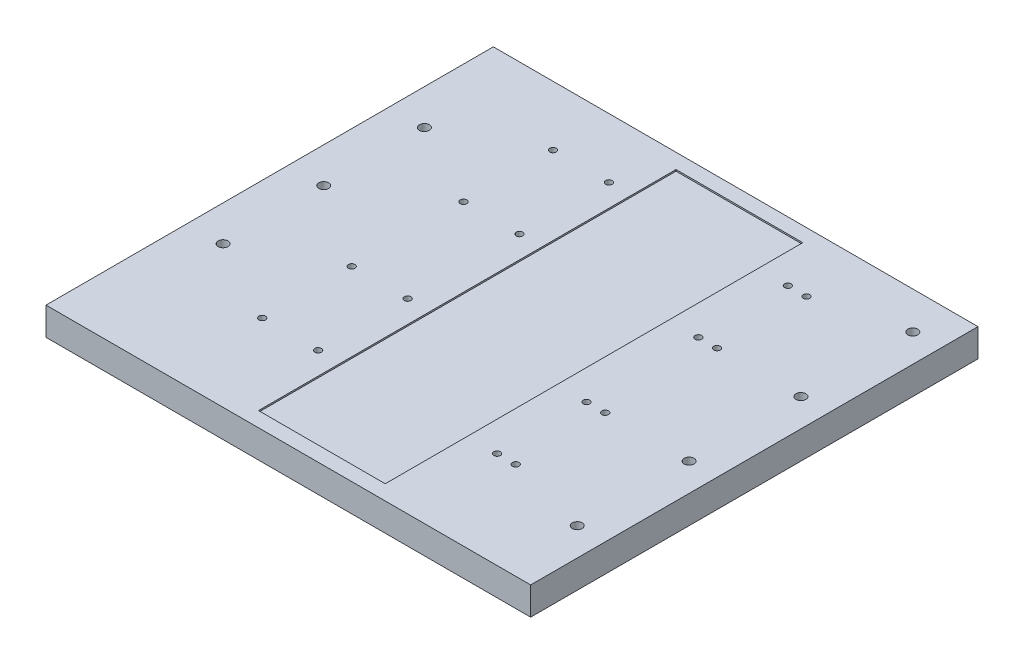
from build123d import *

# Parameters (mm, degrees)
SKETCH1_W                                            = 330.2
SKETCH1_H                                            = 304.8
BOSS_EXTRUDE1_DEPTH                                  = 19.05
SKETCH2_W                                            = 86.36
SKETCH2_H                                            = 284.48
CUT_EXTRUDE1_DEPTH                                   = 1.016
CBORE_FOR_8_SOCKET_HEAD_CAP_SCREW1_D                 = 4.4958
CBORE_FOR_8_SOCKET_HEAD_CAP_SCREW1_CBORE_D           = 7.9375
CBORE_FOR_8_SOCKET_HEAD_CAP_SCREW1_CBORE_DEPTH       = 4.1656
CBORE_FOR_1_4_BINDING_HEAD_MACHINE_SCREW_D           = 6.7564
CBORE_FOR_1_4_BINDING_HEAD_MACHINE_SCREW_CBORE_D     = 14.2875
CBORE_FOR_1_4_BINDING_HEAD_MACHINE_SCREW_CBORE_DEPTH = 4.191


with BuildPart() as part:
    # Sketch1 → Boss-Extrude1 (new body)
    with BuildSketch(Plane(origin=(0, 0, 0), x_dir=(1, 0, 0), z_dir=(0, 1, 0))):
        with Locations((165.1, -152.4)):
            Rectangle(SKETCH1_W, SKETCH1_H)
    extrude(amount=BOSS_EXTRUDE1_DEPTH)

    # Sketch2 → Cut-Extrude1 (cut)
    with BuildSketch(Plane(origin=(0, 19.05, 0), x_dir=(1, 0, 0), z_dir=(0, 1, 0))):
        with Locations((177.8, -152.4)):
            Rectangle(SKETCH2_W, SKETCH2_H)
    extrude(amount=-CUT_EXTRUDE1_DEPTH, mode=Mode.SUBTRACT)

    # CBORE for #8 Socket Head Cap Screw1 (through all)
    with Locations(Plane(origin=(0, 0, 0), x_dir=(-1, 0, 0), z_dir=(0, -1, 0))):
        with Locations((-241.3, -40.64), (-254, -40.64), (-254, -101.6), (-241.3, -101.6), (-241.3, -177.8), (-254, -177.8), (-254, -238.76), (-241.3, -238.76), (-119.38, -40.64), (-81.28, -40.64), (-81.28, -101.6), (-119.38, -101.6), (-119.38, -177.8), (-81.28, -177.8), (-81.28, -238.76), (-119.38, -238.76)):
            CounterBoreHole(CBORE_FOR_8_SOCKET_HEAD_CAP_SCREW1_D / 2, CBORE_FOR_8_SOCKET_HEAD_CAP_SCREW1_CBORE_D / 2, CBORE_FOR_8_SOCKET_HEAD_CAP_SCREW1_CBORE_DEPTH)

    # CBORE for 1/4 Binding Head Machine Screw1 (through all)
    with Locations(Plane(origin=(0, 0, 0), x_dir=(-1, 0, 0), z_dir=(0, -1, 0))):
        with Locations((-311.15, -25.4), (-311.15, -101.6), (-311.15, -177.8), (-311.15, -254), (-24.13, -71.12), (-24.13, -139.7), (-24.13, -208.28)):
            CounterBoreHole(CBORE_FOR_1_4_BINDING_HEAD_MACHINE_SCREW_D / 2, CBORE_FOR_1_4_BINDING_HEAD_MACHINE_SCREW_CBORE_D / 2, CBORE_FOR_1_4_BINDING_HEAD_MACHINE_SCREW_CBORE_DEPTH)


solid = part.part
